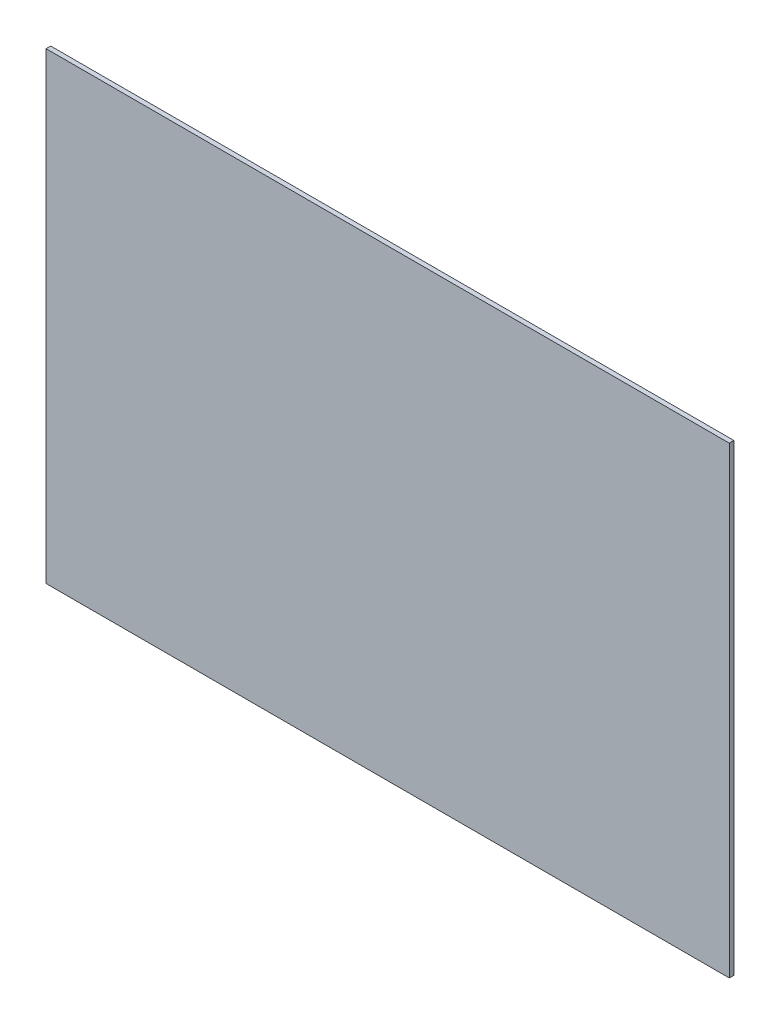
from build123d import *

# Parameters (mm, degrees)
SKETCH1_W           = 295
SKETCH1_H           = 200
BOSS_EXTRUDE1_DEPTH = 2


with BuildPart() as part:
    # Sketch1 → Boss-Extrude1 (new body)
    with BuildSketch(Plane.XY):
        with Locations((147.5, 100)):
            Rectangle(SKETCH1_W, SKETCH1_H)
    extrude(amount=BOSS_EXTRUDE1_DEPTH)


solid = part.part
